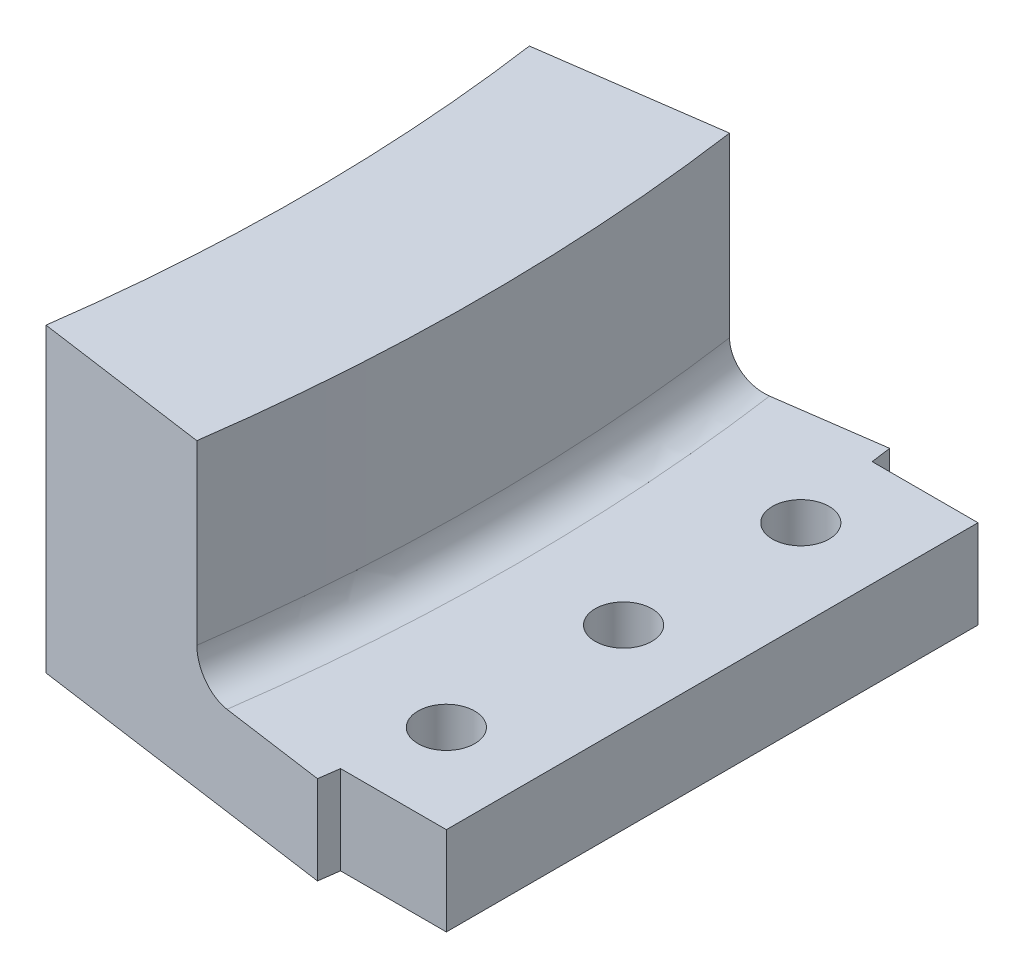
from build123d import *

# Parameters (mm, degrees)
REVOLVE1_ANGLE                 = 16
SKETCH4_W                      = 10
SKETCH4_H                      = 5
MAKERBEAMSUPPORT_DEPTH         = 10
SKETCH5_R                      = 1.6
MAKERBEAMHOLE_DEPTH            = 124.250279147
MAKERBEAMHOLELINEARRIGHT_COUNT = 2
MAKERBEAMHOLELINEARRIGHT_PITCH = 10
MIRROR3_COPY_1_SKETCH_W        = 10
MIRROR3_COPY_1_SKETCH_H        = 5
MIRROR3_COPY_1_DEPTH           = 10
MIRROR3_COPY_2_SKETCH_R        = 1.6
MIRROR3_COPY_2_DEPTH           = 124.250279147
MIRROR3_COPY_3_SKETCH_W        = 10
MIRROR3_COPY_3_SKETCH_H        = 5
MIRROR3_COPY_3_DEPTH           = 10
FILLET7_R                      = 2
SKETCH8_R                      = 1.6
CUT_EXTRUDE8_DEPTH             = 123.660634719


with BuildPart() as part:
    # Sketch1 → Revolve1 (revolve, symmetric)
    with BuildSketch(Plane.XY) as revolve1_sk:
        Polygon((98, 17), (98, 0), (116, 0), (116, 5), (108, 5), (108, 17), align=None)
    revolve(axis=Axis((0, -55, 0), (0, 1, 0)), revolution_arc=REVOLVE1_ANGLE / 2)
    revolve(revolve1_sk.sketch, axis=Axis((0, -55, 0), (0, -1, 0)), revolution_arc=REVOLVE1_ANGLE / 2)

    # Sketch4 → MakerBeamSupport (add)
    with BuildSketch(Plane(origin=(111, 0, 0), x_dir=(0, 0, -1), z_dir=(1, 0, 0))):
        with Locations((0, 2.5)):
            Rectangle(SKETCH4_W, SKETCH4_H)
    makerbeamsupport = extrude(amount=MAKERBEAMSUPPORT_DEPTH)

    # Sketch5 → MakerBeamHole (cut, through all)
    with BuildSketch(Plane(origin=(0, 0, 0), x_dir=(-1, 0, 0), z_dir=(0, -1, 0))):
        with Locations((-116, 0)):
            Circle(SKETCH5_R)
    makerbeamhole = extrude(amount=-MAKERBEAMHOLE_DEPTH, mode=Mode.SUBTRACT)

    # MakerBeamHoleLinearRight: MakerBeamSupport, MakerBeamHole ×2
    with Locations(*[(0, 0, -i * MAKERBEAMHOLELINEARRIGHT_PITCH) for i in range(1, MAKERBEAMHOLELINEARRIGHT_COUNT)]):
        add(makerbeamsupport)
        add(makerbeamhole, mode=Mode.SUBTRACT)

    # Mirror3: MakerBeamHole across plane
    add(makerbeamhole.mirror(Plane.XY), mode=Mode.SUBTRACT)

    # Mirror3 copy 1 sketch → Mirror3 copy 1 (add)
    with BuildSketch(Plane(origin=(111, 0, 10), x_dir=(0, 0, 1), z_dir=(1, 0, 0))):
        with Locations((0, -2.5)):
            Rectangle(MIRROR3_COPY_1_SKETCH_W, MIRROR3_COPY_1_SKETCH_H)
    extrude(amount=MIRROR3_COPY_1_DEPTH)

    # Mirror3 copy 2 sketch → Mirror3 copy 2 (cut, through all)
    with BuildSketch(Plane(origin=(0, 0, 10), x_dir=(-1, 0, 0), z_dir=(0, -1, 0))):
        with Locations((-116, 0)):
            Circle(MIRROR3_COPY_2_SKETCH_R)
    extrude(amount=-MIRROR3_COPY_2_DEPTH, mode=Mode.SUBTRACT)

    # Mirror3 copy 3 sketch → Mirror3 copy 3 (add)
    with BuildSketch(Plane(origin=(111, 0, 0), x_dir=(0, 0, 1), z_dir=(1, 0, 0))):
        with Locations((0, -2.5)):
            Rectangle(MIRROR3_COPY_3_SKETCH_W, MIRROR3_COPY_3_SKETCH_H)
    extrude(amount=MIRROR3_COPY_3_DEPTH)

    # Fillet7
    fillet7_edges = [part.edges().sort_by_distance(p)[0] for p in [
        (108, 5, 0),
    ]]
    fillet(fillet7_edges, radius=FILLET7_R)

    # Sketch8 → Cut-Extrude8 (cut, through all)
    with BuildSketch(Plane(origin=(0, 5, 0), x_dir=(1, 0, 0), z_dir=(0, 1, 0))):
        with Locations((116, 0)):
            Circle(SKETCH8_R)
    extrude(amount=-CUT_EXTRUDE8_DEPTH, mode=Mode.SUBTRACT)


solid = part.part
